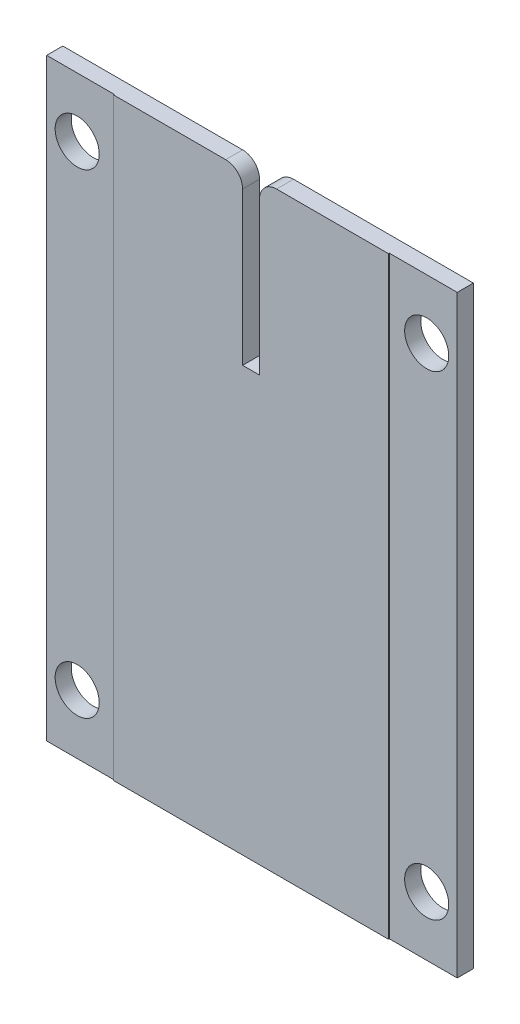
from build123d import *

# Parameters (mm, degrees)
SKETCH1_W           = 242
SKETCH1_H           = 350
SKETCH1_R           = 13
BOSS_EXTRUDE1_DEPTH = 10
SKETCH2_W           = 40
SKETCH2_H           = 350
CUT_EXTRUDE1_DEPTH  = 0.5
SKETCH3_W           = 10
SKETCH3_H           = 100
CUT_EXTRUDE2_DEPTH  = 11
FILLET1_R           = 10


with BuildPart() as part:
    # Sketch1 → Boss-Extrude1 (new body)
    with BuildSketch(Plane.XY):
        Rectangle(SKETCH1_W, SKETCH1_H)
        with Locations((-103, 140)):
            Circle(SKETCH1_R, mode=Mode.SUBTRACT)
        with Locations((-103, -140)):
            Circle(SKETCH1_R, mode=Mode.SUBTRACT)
        with Locations((103, 140)):
            Circle(SKETCH1_R, mode=Mode.SUBTRACT)
        with Locations((103, -140)):
            Circle(SKETCH1_R, mode=Mode.SUBTRACT)
    extrude(amount=BOSS_EXTRUDE1_DEPTH)

    # Sketch2 → Cut-Extrude1 (cut)
    with BuildSketch(Plane.XY.offset(10)):
        with Locations((-101, 0)):
            Rectangle(SKETCH2_W, SKETCH2_H)
        with Locations((101, 0)):
            Rectangle(SKETCH2_W, SKETCH2_H)
    extrude(amount=-CUT_EXTRUDE1_DEPTH, mode=Mode.SUBTRACT)

    # Sketch3 → Cut-Extrude2 (cut, through all)
    with BuildSketch(Plane.XY.offset(10)):
        with Locations((0, 125)):
            Rectangle(SKETCH3_W, SKETCH3_H)
    extrude(amount=-CUT_EXTRUDE2_DEPTH, mode=Mode.SUBTRACT)

    # Fillet1
    fillet1_edges = [part.edges().sort_by_distance(p)[0] for p in [
        (5, 175, 5),
        (-5, 175, 5),
    ]]
    fillet(fillet1_edges, radius=FILLET1_R)


solid = part.part
